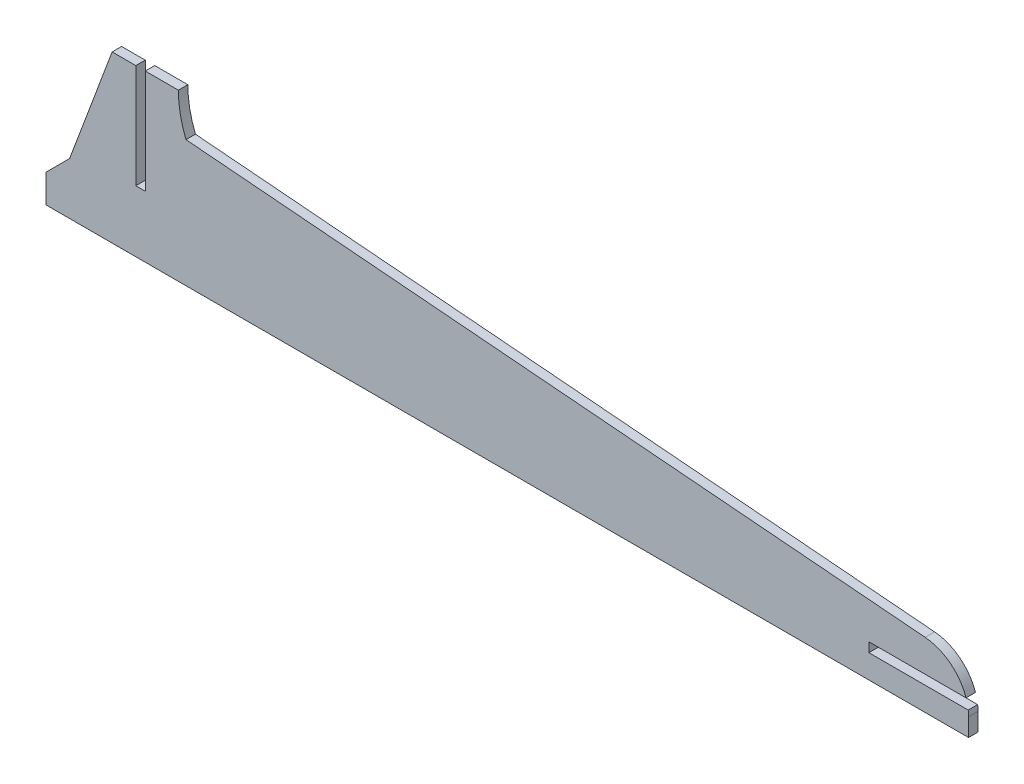
from build123d import *

# Parameters (mm, degrees)
RESSALTO_EXTRUS_O1_DEPTH = 2


with BuildPart() as part:
    # Esboço1 → Ressalto-extrusão1 (new body)
    with BuildSketch(Plane.XY):
        with BuildLine():
            Line((-99.38960786, -14.180843063), (-99.38960786, -8.180843063))
            Line((-99.38960786, -8.180843063), (-94.38960786, -3.180843063))
            Line((-94.38960786, -3.180843063), (-85.410682211, 20.819156937))
            Line((-85.410682211, 20.819156937), (-80.410682211, 20.819156937))
            Line((-80.410682211, 20.819156937), (-80.410682211, -1.180843063))
            Line((-80.410682211, -1.180843063), (-78.410682211, -1.180843063))
            Line((-78.410682211, -1.180843063), (-78.410682211, 20.819156937))
            Line((-78.410682211, 20.819156937), (-71.410682211, 20.819156937))
            ThreePointArc((-71.410682211, 20.819156937), (-71.004691587, 16.614538042), (-69.801720857, 12.565277632))
            Line((-69.801720857, 12.565277632), (86.438560019, -0.41864307))
            ThreePointArc((86.438560019, -0.41864307), (91.771593682, -2.507769172), (95.083402302, -7.180843063))
            Line((95.083402302, -7.180843063), (74.537713689, -7.180843063))
            Line((74.537713689, -7.180843063), (74.537713689, -9.180843063))
            Line((74.537713689, -9.180843063), (95.537713689, -9.180843063))
            ThreePointArc((95.537713689, -9.180843063), (95.59220599, -9.781470716), (95.61039214, -10.384290965))
            Line((95.61039214, -10.384290965), (95.61039214, -14.180843063))
            Line((95.61039214, -14.180843063), (-99.38960786, -14.180843063))
        make_face()
    extrude(amount=RESSALTO_EXTRUS_O1_DEPTH)


solid = part.part
